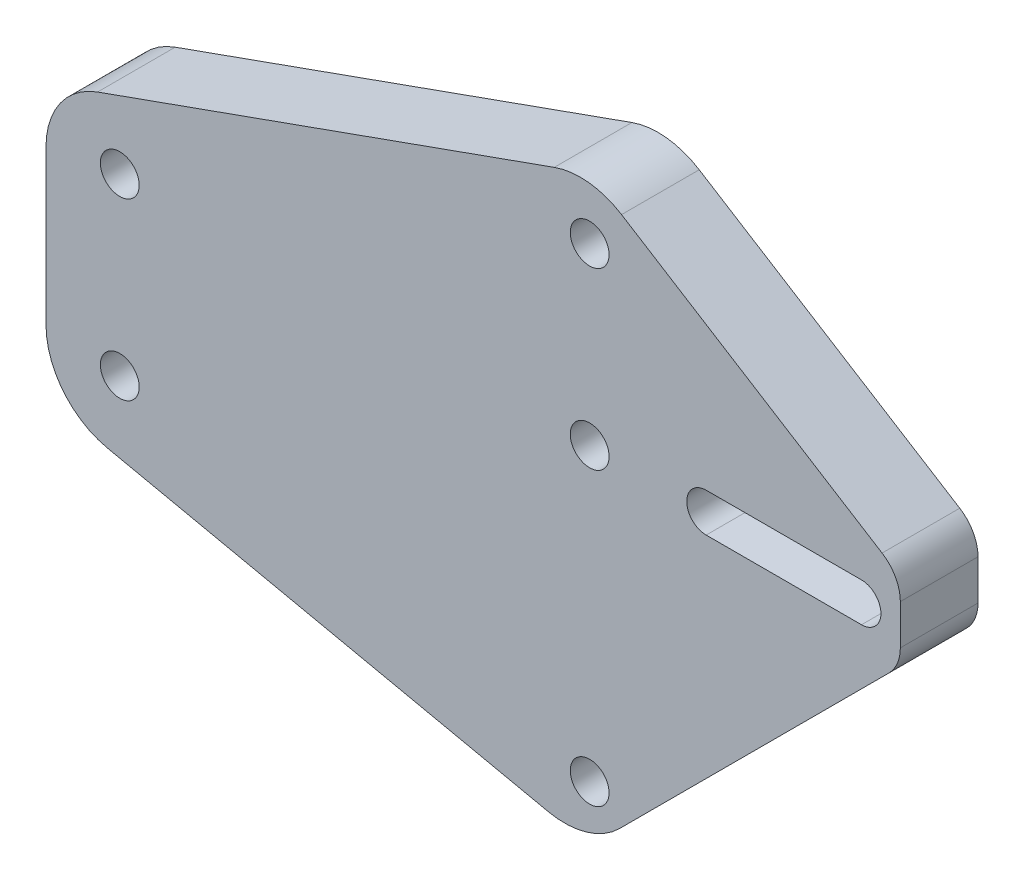
from build123d import *

# Parameters (mm, degrees)
SKETCH1_R           = 2.5
BOSS_EXTRUDE2_DEPTH = 10


with BuildPart() as part:
    # Sketch1 → Boss-Extrude2 (new body)
    with BuildSketch(Plane.XY):
        with BuildLine():
            Line((-44.558562685, 33.371941898), (-103.36336397, 12.370227154))
            ThreePointArc((-103.36336397, 12.370227154), (-108.174155605, 8.713292405), (-110, 2.952808038))
            Line((-110, 2.952808038), (-110, -16.915842098))
            ThreePointArc((-110, -16.915842098), (-107.77666088, -23.202617548), (-102.095290887, -26.693866238))
            Line((-102.095290887, -26.693866238), (-45.319507834, -38.860105464))
            ThreePointArc((-45.319507834, -38.860105464), (-40.391993061, -38.672623949), (-36.153149135, -36.153149135))
            Line((-36.153149135, -36.153149135), (-1.464466094, -1.464466094))
            ThreePointArc((-1.464466094, -1.464466094), (-0.380602337, 0.15765065), (0, 2.071067812))
            Line((0, 2.071067812), (0, 7.228761792))
            ThreePointArc((0, 7.228761792), (-0.626787594, 9.652604454), (-2.3500053, 11.468753312))
            Line((-2.3500053, 11.468753312), (-35.895209315, 32.434505822))
            ThreePointArc((-35.895209315, 32.434505822), (-40.119407791, 33.896488075), (-44.558562685, 33.371941898))
        make_face()
        with Locations((-40, 4.649914802)):
            Circle(SKETCH1_R, mode=Mode.SUBTRACT)
        with Locations((-40, 27.149914802)):
            Circle(SKETCH1_R, mode=Mode.SUBTRACT)
        with Locations((-100.5, 4.649914802)):
            Circle(SKETCH1_R, mode=Mode.SUBTRACT)
        with Locations((-100.5, -17.850085198)):
            Circle(SKETCH1_R, mode=Mode.SUBTRACT)
        with Locations((-40, -32.850085198)):
            Circle(SKETCH1_R, mode=Mode.SUBTRACT)
        with BuildLine():
            Line((-25, 7.149914802), (-5, 7.149914802))
            ThreePointArc((-5, 7.149914802), (-2.5, 4.649914802), (-5, 2.149914802))
            Line((-5, 2.149914802), (-25, 2.149914802))
            ThreePointArc((-25, 2.149914802), (-27.5, 4.649914802), (-25, 7.149914802))
        make_face(mode=Mode.SUBTRACT)
    extrude(amount=BOSS_EXTRUDE2_DEPTH)


solid = part.part
